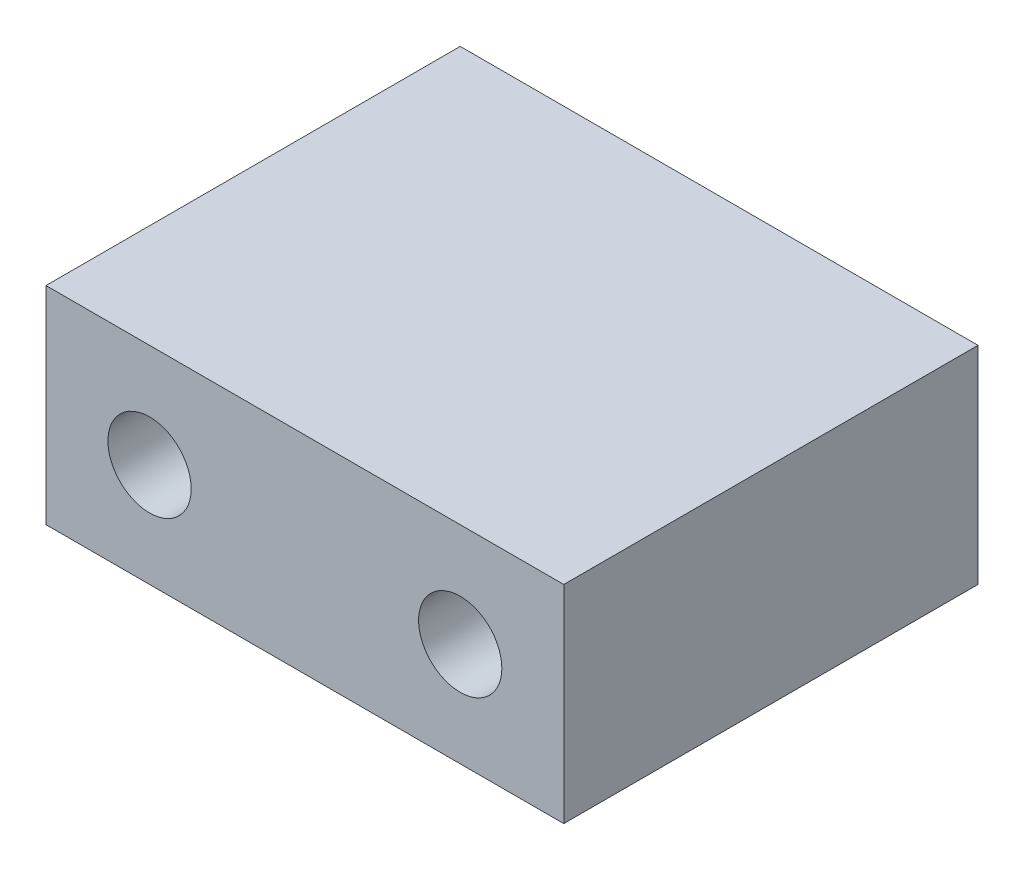
from build123d import *

# Parameters (mm, degrees)
SKETCH1_W                   = 31.75
SKETCH1_H                   = 12.7
BOSS_EXTRUDE1_DEPTH         = 25.4
F_1_4_20_TAPPED_HOLE1_D     = 5.1054
F_1_4_20_TAPPED_HOLE1_DEPTH = 16.51
F_1_4_20_TAPPED_HOLE1_TIP   = 1.533816902


with BuildPart() as part:
    # Sketch1 → Boss-Extrude1 (new body)
    with BuildSketch(Plane.XY):
        Rectangle(SKETCH1_W, SKETCH1_H)
    extrude(amount=BOSS_EXTRUDE1_DEPTH)

    # 1/4-20 Tapped Hole1
    with Locations(Plane.XY.offset(25.4)):
        with Locations((-9.525, 0), (9.525, 0)):
            Hole(F_1_4_20_TAPPED_HOLE1_D / 2, depth=F_1_4_20_TAPPED_HOLE1_DEPTH)
            with Locations((0, 0, -(F_1_4_20_TAPPED_HOLE1_DEPTH + F_1_4_20_TAPPED_HOLE1_TIP / 2))):  # 118° drill point
                Cone(0, F_1_4_20_TAPPED_HOLE1_D / 2, F_1_4_20_TAPPED_HOLE1_TIP, mode=Mode.SUBTRACT)


solid = part.part
